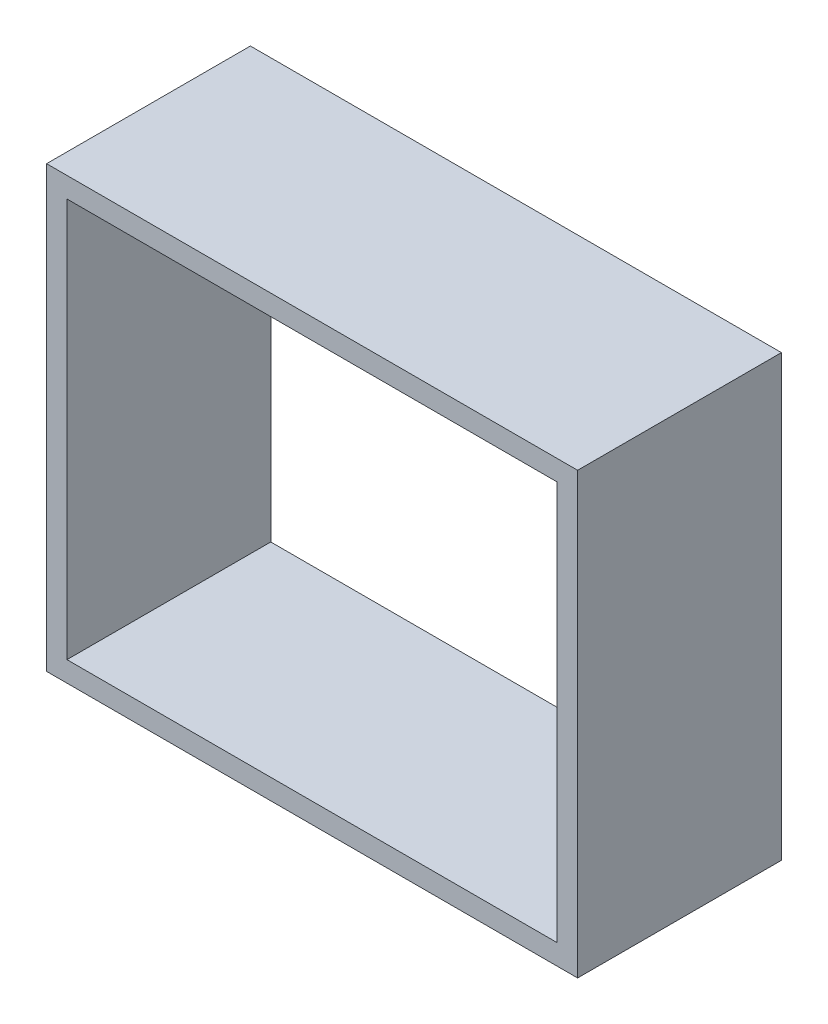
from build123d import *

# Parameters (mm, degrees)
SKETCH1_W           = 130.283701958
SKETCH1_H           = 107.878622698
SKETCH1_W_2         = 120.283701958
SKETCH1_H_2         = 97.878622698
BOSS_EXTRUDE1_DEPTH = 50


with BuildPart() as part:
    # Sketch1 → Boss-Extrude1 (new body)
    with BuildSketch(Plane.XY):
        with Locations((32.414578252, 16.590826501)):
            Rectangle(SKETCH1_W, SKETCH1_H)
        with Locations((32.414578252, 16.590826501)):
            Rectangle(SKETCH1_W_2, SKETCH1_H_2, mode=Mode.SUBTRACT)
    extrude(amount=BOSS_EXTRUDE1_DEPTH)


solid = part.part
